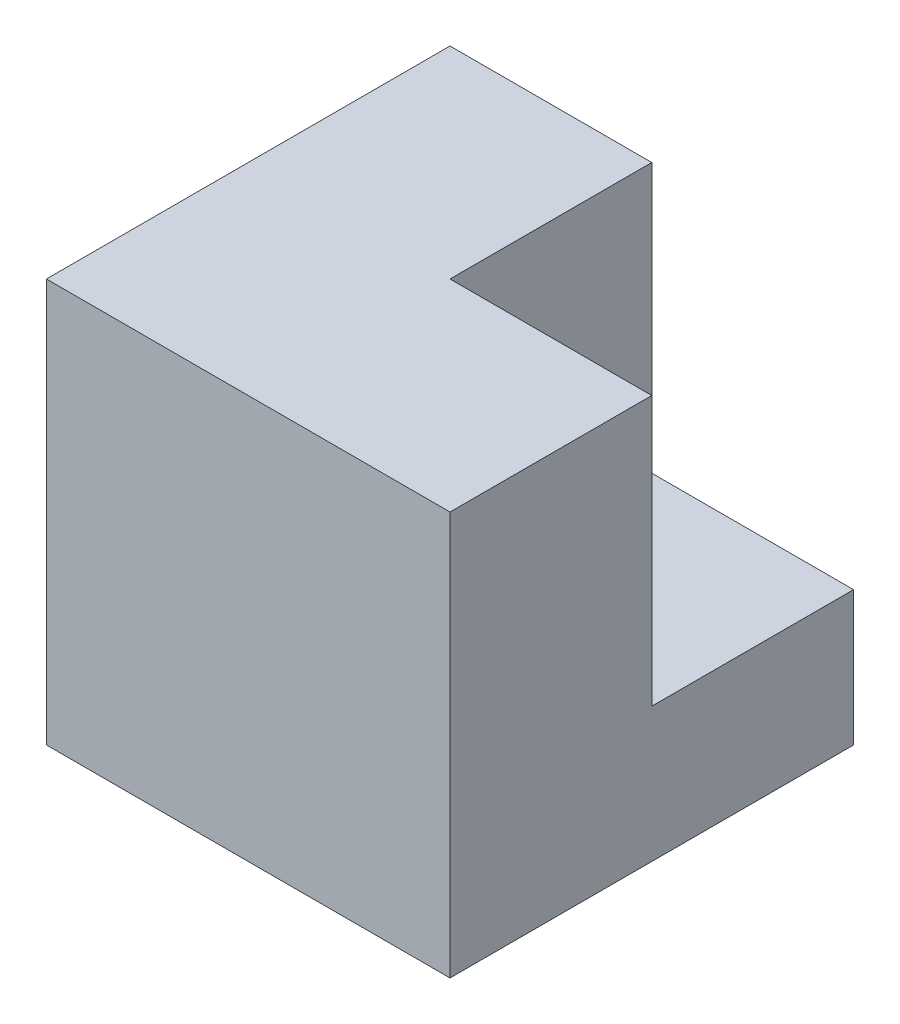
from build123d import *

# Parameters (mm, degrees)
SKETCH1_W           = 76.2
SKETCH1_H           = 76.2
BOSS_EXTRUDE1_DEPTH = 76.2
SKETCH2_W           = 38.1
SKETCH2_H           = 50.8
CUT_EXTRUDE1_DEPTH  = 38.1


with BuildPart() as part:
    # Sketch1 → Boss-Extrude1 (new body)
    with BuildSketch(Plane.XY):
        with Locations((38.1, 38.1)):
            Rectangle(SKETCH1_W, SKETCH1_H)
    extrude(amount=BOSS_EXTRUDE1_DEPTH)

    # Sketch2 → Cut-Extrude1 (cut)
    with BuildSketch(Plane(origin=(76.2, 0, 0), x_dir=(0, 0, -1), z_dir=(1, 0, 0))):
        with Locations((-19.05, 50.8)):
            Rectangle(SKETCH2_W, SKETCH2_H)
    extrude(amount=-CUT_EXTRUDE1_DEPTH, mode=Mode.SUBTRACT)


solid = part.part
